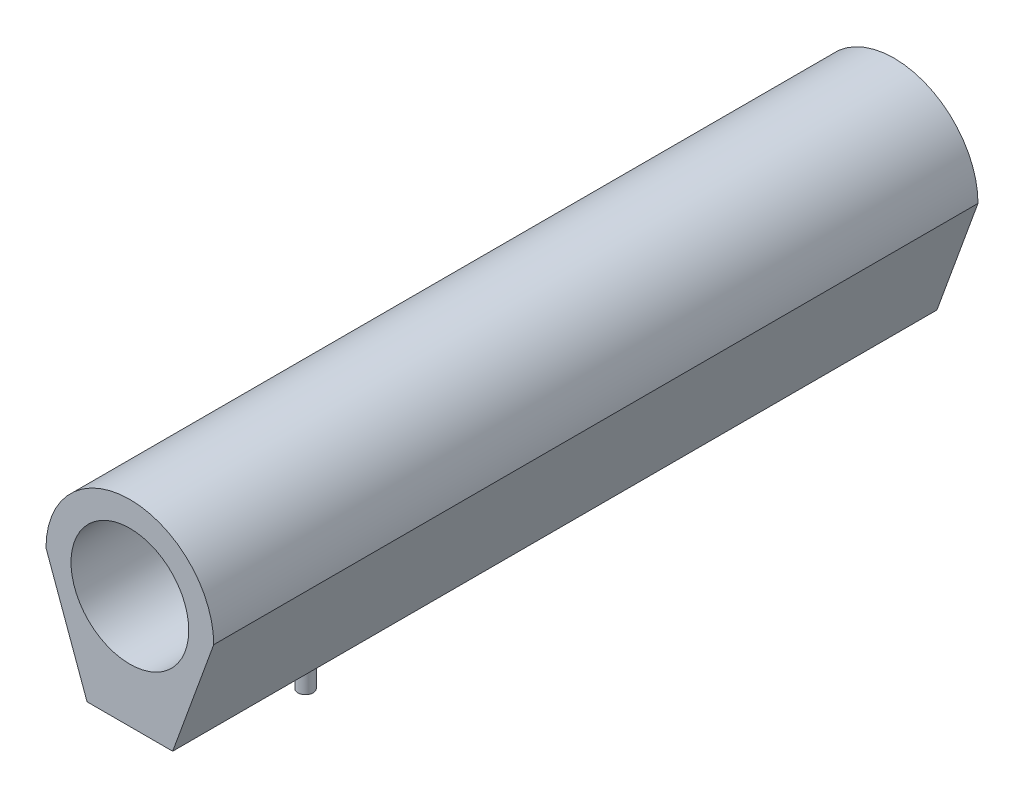
from build123d import *

# Parameters (mm, degrees)
SKETCH1_R  = 9.65
BODY_DEPTH = 125.3


with BuildPart() as part:
    # Sketch1 → Body (new body)
    with BuildSketch(Plane.XY.offset(125.3)):
        with BuildLine():
            Line((-7.016550666, -18.5), (7.016550666, -18.5))
            Line((7.016550666, -18.5), (13.75, 0))
            ThreePointArc((13.75, 0), (0, 13.75), (-13.75, 0))
            Line((-13.75, 0), (-7.016550666, -18.5))
        make_face()
        Circle(SKETCH1_R, mode=Mode.SUBTRACT)
    extrude(amount=-BODY_DEPTH)

    # Sketch2 → Electric-Output (revolve)
    with BuildSketch(Plane(origin=(0, 0, 0), x_dir=(0, 0, -1), z_dir=(1, 0, 0))):
        Polygon((-91.921275864, -20.75), (-90.75, -18.5), (-96.5, -18.5), (-96.5, -23), (-96.5, -27.5), (-95.25, -27.5), (-95.25, -23), (-94.25, -23), (-93.078724136, -20.75), align=None)
    revolve(axis=Axis((0, -23, 96.5), (0, 1, 0)))


solid = part.part
